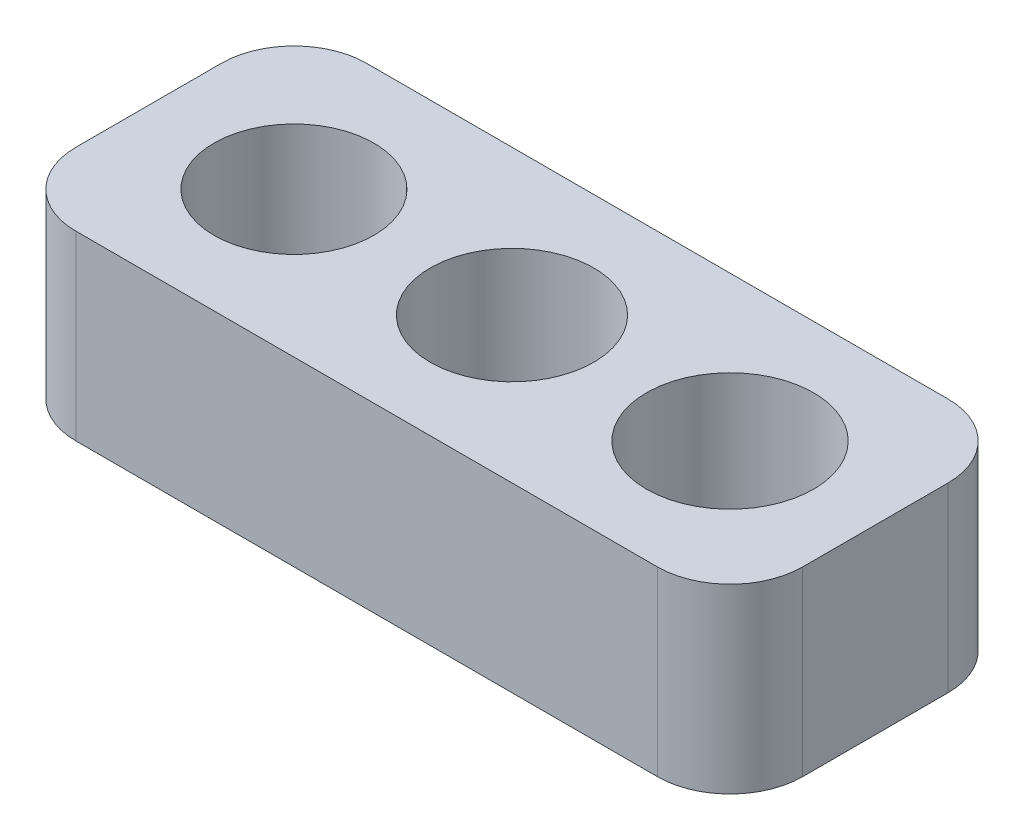
from build123d import *

# Parameters (mm, degrees)
SKETCH1_W           = 20
SKETCH1_H           = 8
SKETCH1_R           = 2.2
SKETCH1_R_2         = 2.25
SKETCH1_R_3         = 2.3
BOSS_EXTRUDE1_DEPTH = 5
FILLET1_R           = 2


with BuildPart() as part:
    # Sketch1 → Boss-Extrude1 (new body)
    with BuildSketch(Plane(origin=(0, 0, 0), x_dir=(1, 0, 0), z_dir=(0, 1, 0))):
        Rectangle(SKETCH1_W, SKETCH1_H)
        with Locations((-6, 0)):
            Circle(SKETCH1_R, mode=Mode.SUBTRACT)
        Circle(SKETCH1_R_2, mode=Mode.SUBTRACT)
        with Locations((6, 0)):
            Circle(SKETCH1_R_3, mode=Mode.SUBTRACT)
    extrude(amount=BOSS_EXTRUDE1_DEPTH)

    # Fillet1
    fillet1_edges = [part.edges().sort_by_distance(p)[0] for p in [
        (-10, 2.5, -4),
        (-10, 2.5, 4),
        (10, 2.5, -4),
        (10, 2.5, 4),
    ]]
    fillet(fillet1_edges, radius=FILLET1_R)


solid = part.part
